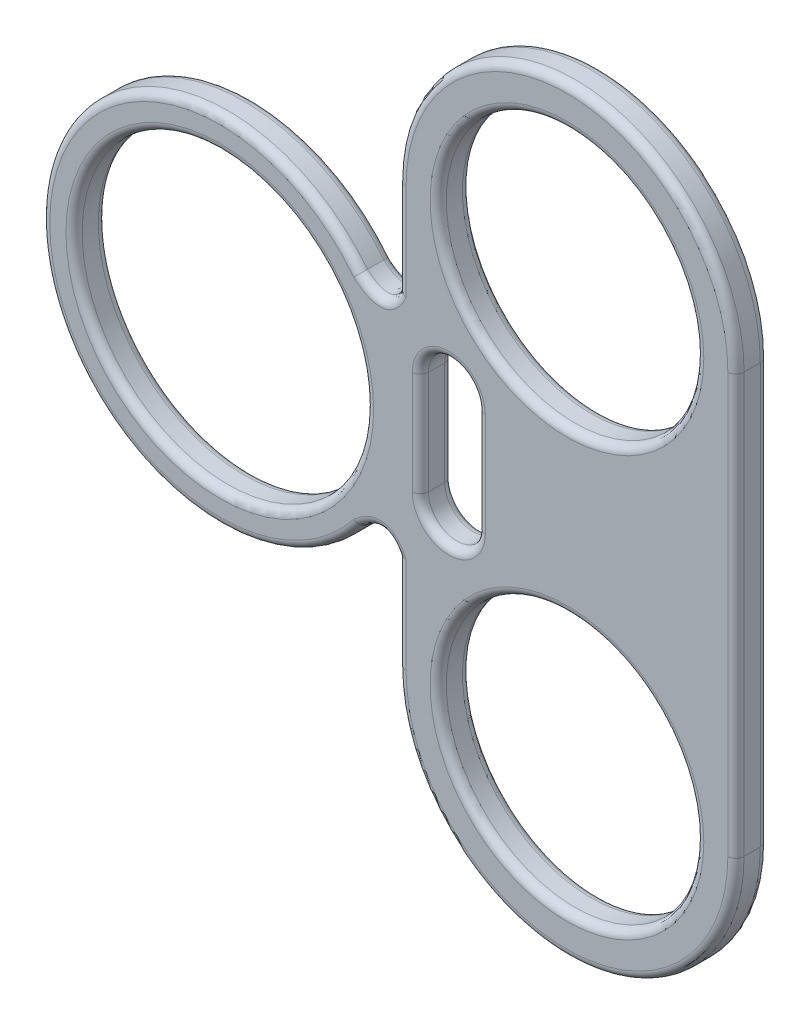
from build123d import *

# Parameters (mm, degrees)
CROQUIS1_R              = 9
CROQUIS1_R_2            = 7.95
SALIENTE_EXTRUIR1_DEPTH = 2
REDONDEO1_R             = 0.5


with BuildPart() as part:
    # Croquis1 → Saliente-Extruir1 (new body)
    with BuildSketch(Plane.XY.offset(2.563176866)):
        with BuildLine():
            Line((-27.738044373, 15.390531156), (-27.738044373, 9.55))
            ThreePointArc((-27.738044373, 9.55), (-17.302128625, -0.885915747), (-6.866212878, 9.55))
            Line((-6.866212878, 9.55), (-6.866212878, 35.45))
            ThreePointArc((-6.866212878, 35.45), (-17.302128625, 45.885915747), (-27.738044373, 35.45))
            Line((-27.738044373, 35.45), (-27.738044373, 29.609468845))
            add(Edge.make_bspline(
                [(-30.109245734, 29.322304161), (-28.549959947, 27.967841138), (-27.738044373, 29.609468845)],
                knots=[0, 0, 0, 1, 1, 1], degree=2))
            ThreePointArc((-30.109245734, 29.322304161), (-49.738044373, 22.5), (-30.109245734, 15.677695839))
            add(Edge.make_bspline(
                [(-30.109245734, 15.677695839), (-28.549959947, 17.032158863), (-27.738044373, 15.390531156)],
                knots=[0, 0, 0, 1, 1, 1], degree=2))
        make_face()
        with Locations((-38.738044373, 22.5)):
            Circle(CROQUIS1_R, mode=Mode.SUBTRACT)
        with Locations((-17.302128625, 35.45)):
            Circle(CROQUIS1_R_2, mode=Mode.SUBTRACT)
        with Locations((-17.302128625, 9.55)):
            Circle(CROQUIS1_R_2, mode=Mode.SUBTRACT)
        with BuildLine():
            Line((-22.842128625, 19.305), (-22.842128625, 25.695))
            ThreePointArc((-22.842128625, 25.695), (-24.597128625, 27.45), (-26.352128625, 25.695))
            Line((-26.352128625, 25.695), (-26.352128625, 19.305))
            ThreePointArc((-26.352128625, 19.305), (-24.597128625, 17.55), (-22.842128625, 19.305))
        make_face(mode=Mode.SUBTRACT)
    extrude(amount=SALIENTE_EXTRUIR1_DEPTH)

    # Redondeo1
    redondeo1_edges = [part.edges().sort_by_distance(p)[0] for p in [
        (-49.738044373, 22.5, 2.563176866),
        (-28.80915391, 28.710921388, 2.563176866),
        (-27.738044373, 32.529734422, 2.563176866),
        (-17.302128625, 45.885915747, 2.563176866),
        (-28.80915391, 28.710921388, 4.563176866),
        (-49.738044373, 22.5, 4.563176866),
        (-28.80915391, 16.289078612, 4.563176866),
        (-25.252128625, 35.45, 2.563176866),
        (-25.252128625, 35.45, 4.563176866),
        (-27.738044373, 12.470265578, 4.563176866),
        (-25.252128625, 9.55, 2.563176866),
        (-25.252128625, 9.55, 4.563176866),
        (-17.302128625, -0.885915747, 4.563176866),
        (-47.738044373, 22.5, 2.563176866),
        (-47.738044373, 22.5, 4.563176866),
        (-6.866212878, 22.5, 4.563176866),
        (-24.597128625, 17.55, 2.563176866),
        (-22.842128625, 22.5, 2.563176866),
        (-24.597128625, 27.45, 2.563176866),
        (-26.352128625, 22.5, 2.563176866),
        (-24.597128625, 17.55, 4.563176866),
        (-22.842128625, 22.5, 4.563176866),
        (-24.597128625, 27.45, 4.563176866),
        (-26.352128625, 22.5, 4.563176866),
        (-17.302128625, 45.885915747, 4.563176866),
        (-6.866212878, 22.5, 2.563176866),
        (-27.738044373, 32.529734422, 4.563176866),
        (-17.302128625, -0.885915747, 2.563176866),
        (-27.738044373, 12.470265578, 2.563176866),
        (-28.80915391, 16.289078612, 2.563176866),
    ]]
    fillet(redondeo1_edges, radius=REDONDEO1_R)


solid = part.part
